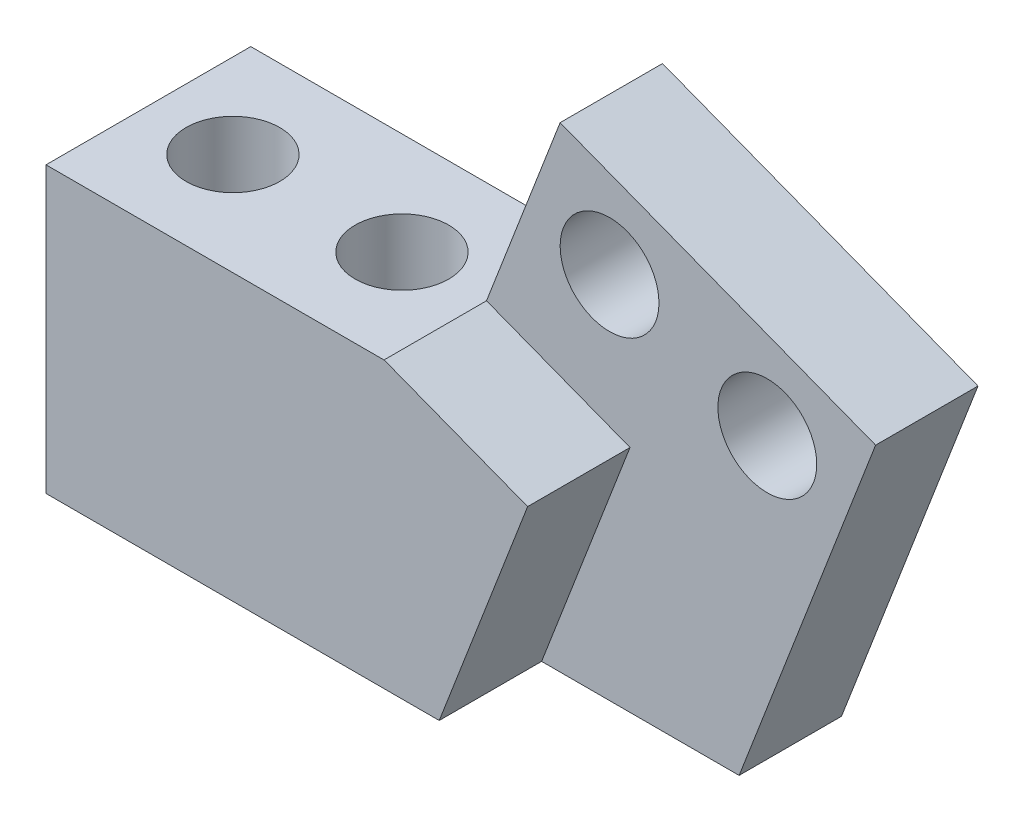
from build123d import *

# Parameters (mm, degrees)
BASE_EXTRUDE_DEPTH                           = 5
CUTAWAY_FOR_CLAMP_PLATE_WIRE_DEPTH           = 5
SKETCH3_R                                    = 2.413
CLAMP_PLATE_HOLES_ALTERED_TO_10_24_OCT_DEPTH = 5
HOLES_TO_PITCH_PLATE_REACH                   = 15.9
SKETCH4_R                                    = 2.286


with BuildPart() as part:
    # Sketch1 → Base-Extrude (new body, symmetric)
    with BuildSketch(Plane.XY):
        Polygon((-7.703086391, 2.967740731), (0, 0), (7.703086391, -2.967740731), (1.037503031, -20.268970563), (-27.810207986, -20.268970563), (-27.810207986, -6.368970563), (-11.300207986, -6.368970563), align=None)
    extrude(amount=BASE_EXTRUDE_DEPTH, both=True)

    # Sketch2 → Cutaway for Clamp Plate & Wire (cut)
    with BuildSketch(Plane.XY.offset(5)):
        Polygon((-7.703086391, 2.967740731), (7.703086391, -2.967740731), (1.037503031, -20.268970563), (-8.607332328, -20.268970563), (-4.290273371, -9.06358535), (-11.298169046, -6.363678277), align=None)
    extrude(amount=-CUTAWAY_FOR_CLAMP_PLATE_WIRE_DEPTH, mode=Mode.SUBTRACT)

    # Sketch3 → Clamp Plate Holes (altered to #10-24 OCT04) (cut)
    with BuildSketch(Plane.XY):
        with Locations((2.413510134, -5.216437969)):
            Circle(SKETCH3_R)
        with Locations((-5.289576257, -2.248697238)):
            Circle(SKETCH3_R)
    extrude(amount=-CLAMP_PLATE_HOLES_ALTERED_TO_10_24_OCT_DEPTH, mode=Mode.SUBTRACT)

    # Sketch4 → Holes to Pitch Plate (cut, up to next)
    with BuildSketch(Plane(origin=(0, -6.368970563, 0), x_dir=(-1, 0, 0), z_dir=(0, 1, 0)), mode=Mode.PRIVATE) as holes_to_pitch_plate_sk1:
        with Locations((23.682707986, 0)):
            Circle(SKETCH4_R)
    holes_to_pitch_plate_tool1 = extrude(holes_to_pitch_plate_sk1.sketch, amount=-HOLES_TO_PITCH_PLATE_REACH, mode=Mode.PRIVATE) & part.part
    add(holes_to_pitch_plate_tool1.solids().sort_by_distance((-23.682708, -6.368971, 0))[0], mode=Mode.SUBTRACT)
    # Sketch4 → Holes to Pitch Plate (cut, up to next)
    with BuildSketch(Plane(origin=(0, -6.368970563, 0), x_dir=(-1, 0, 0), z_dir=(0, 1, 0)), mode=Mode.PRIVATE) as holes_to_pitch_plate_sk2:
        with Locations(Location((15.427707986, 0, 0), (0, 0, 90))):  # turned: the seam where the file's is
            Circle(SKETCH4_R)
    holes_to_pitch_plate_tool2 = extrude(holes_to_pitch_plate_sk2.sketch, amount=-HOLES_TO_PITCH_PLATE_REACH, mode=Mode.PRIVATE) & part.part
    add(holes_to_pitch_plate_tool2.solids().sort_by_distance((-15.427708, -6.368971, 0))[0], mode=Mode.SUBTRACT)


solid = part.part
